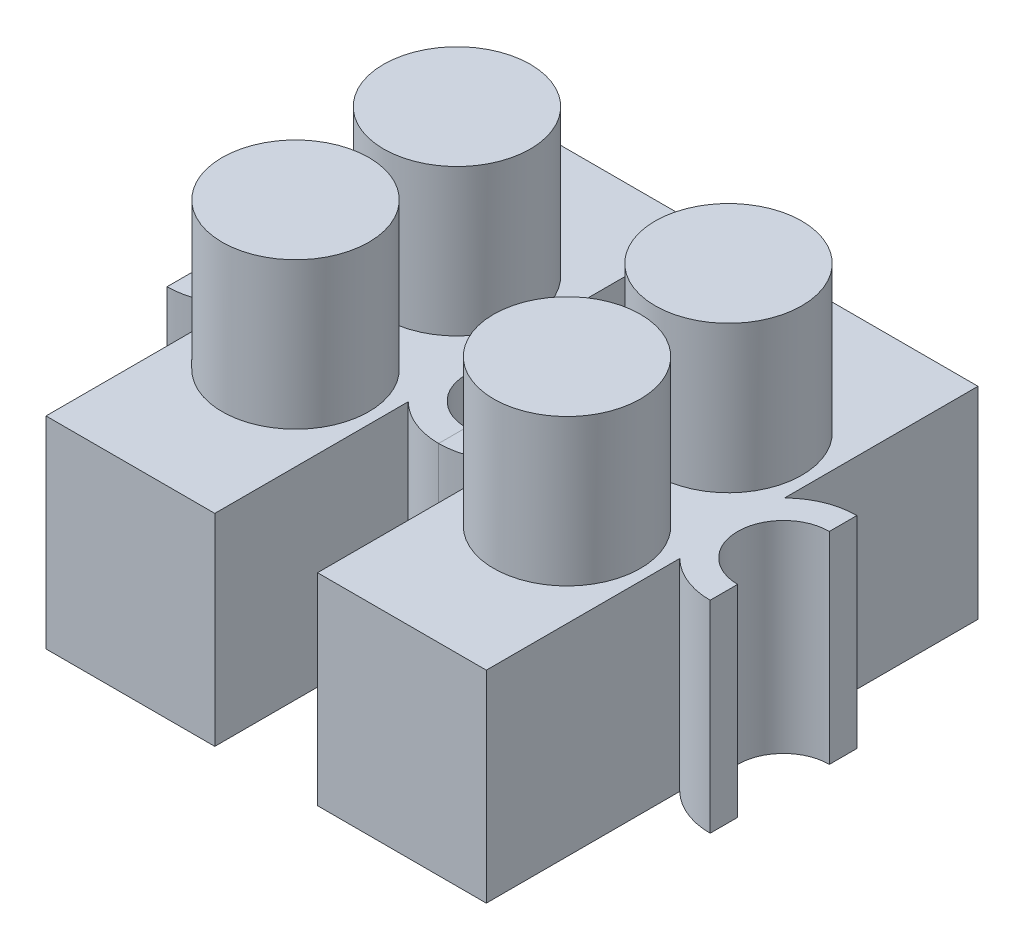
from build123d import *

# Parameters (mm, degrees)
BOSS_EXTRUDE1_DEPTH = 6.985
SKETCH3_W           = 4.572
SKETCH3_H           = 15.494
CUT_EXTRUDE1_DEPTH  = 1.27
SKETCH6_R           = 2.54
BOSS_EXTRUDE3_DEPTH = 5.08
LPATTERN1_COUNT     = 2
LPATTERN1_PITCH     = 9.398


with BuildPart() as part:
    # Sketch2 → Boss-Extrude1 (new body)
    with BuildSketch(Plane(origin=(0, 0, 0), x_dir=(1, 0, 0), z_dir=(0, 1, 0))):
        with BuildLine():
            Line((2.921, 8.509), (-2.921, 8.509))
            Line((-2.921, 8.509), (-2.921, 1.813922821))
            ThreePointArc((-2.921, 1.813922821), (-3.738730237, 2.351485059), (-4.699, 2.54))
            Line((-4.699, 2.54), (-4.699, 1.5875))
            ThreePointArc((-4.699, 1.5875), (-3.1115, 0), (-4.699, -1.5875))
            Line((-4.699, -1.5875), (-4.699, -2.54))
            ThreePointArc((-4.699, -2.54), (-3.738730237, -2.351485059), (-2.921, -1.813922821))
            Line((-2.921, -1.813922821), (-2.921, -8.509))
            Line((-2.921, -8.509), (2.921, -8.509))
            Line((2.921, -8.509), (2.921, -1.813922821))
            ThreePointArc((2.921, -1.813922821), (3.738730237, -2.351485059), (4.699, -2.54))
            Line((4.699, -2.54), (4.699, -1.5875))
            ThreePointArc((4.699, -1.5875), (3.1115, 0), (4.699, 1.5875))
            Line((4.699, 1.5875), (4.699, 2.54))
            ThreePointArc((4.699, 2.54), (3.738730237, 2.351485059), (2.921, 1.813922821))
            Line((2.921, 1.813922821), (2.921, 8.509))
        make_face()
    extrude(amount=BOSS_EXTRUDE1_DEPTH)

    # Sketch3 → Cut-Extrude1 (cut)
    with BuildSketch(Plane.XZ):
        Rectangle(SKETCH3_W, SKETCH3_H)
    extrude(amount=-CUT_EXTRUDE1_DEPTH, mode=Mode.SUBTRACT)

    # Sketch6 → Boss-Extrude3 (add)
    with BuildSketch(Plane(origin=(0, 6.985, 0), x_dir=(1, 0, 0), z_dir=(0, 1, 0))):
        with Locations((0, 2.794)):
            Circle(SKETCH6_R)
        with Locations((0, -2.794)):
            Circle(SKETCH6_R)
    extrude(amount=BOSS_EXTRUDE3_DEPTH)


with BuildPart() as lpattern1_1:
    # LPattern1: pattern copy
    add(part.part.moved(Location(Vector(-1, 0, 0) * (1 * LPATTERN1_PITCH))))


solid = Compound([part.part, lpattern1_1.part])
